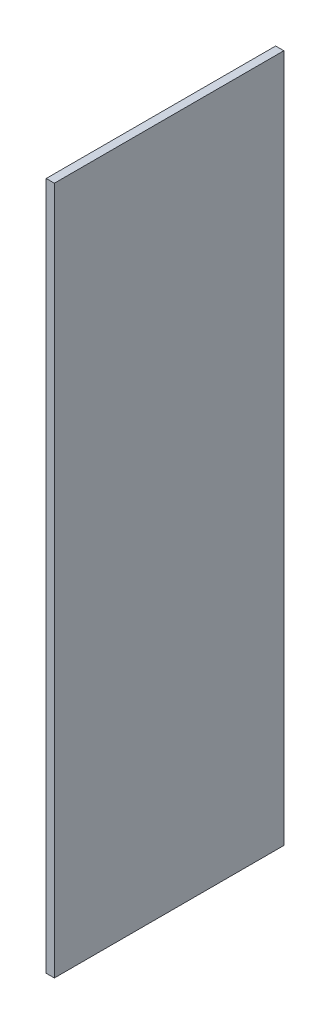
from build123d import *

# Parameters (mm, degrees)
SKETCH1_W           = 88.9
SKETCH1_H           = 266.7
BOSS_EXTRUDE1_DEPTH = 3.175


with BuildPart() as part:
    # Sketch1 → Boss-Extrude1 (new body)
    with BuildSketch(Plane(origin=(0, 0, 0), x_dir=(0, 0, -1), z_dir=(1, 0, 0))):
        with Locations((44.45, 133.35)):
            Rectangle(SKETCH1_W, SKETCH1_H)
    extrude(amount=BOSS_EXTRUDE1_DEPTH)


solid = part.part
